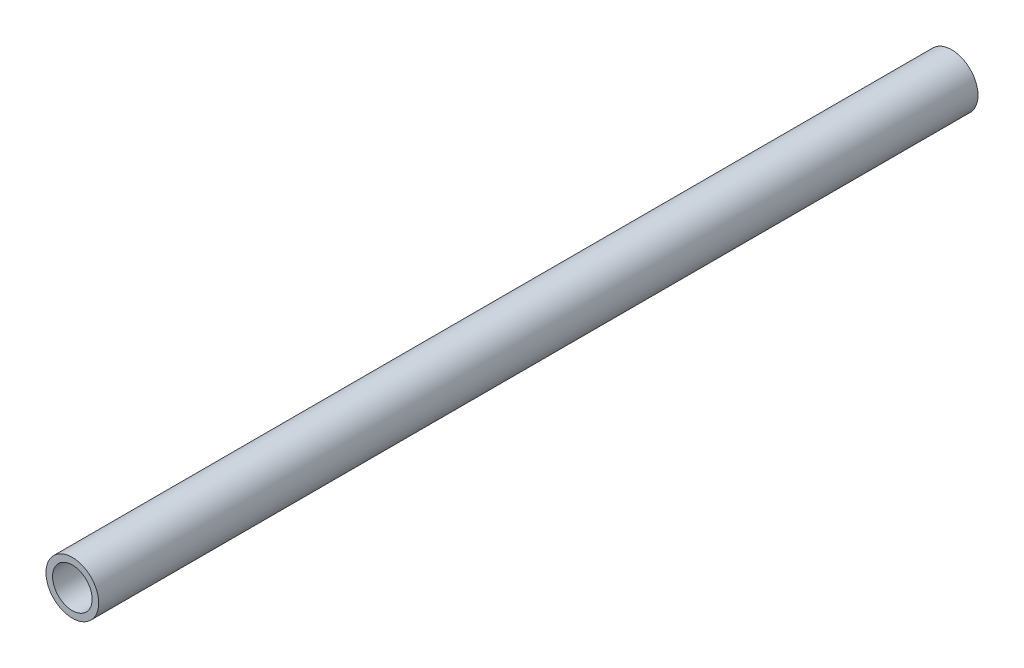
from build123d import *

# Parameters (mm, degrees)
CROQUIS1_R              = 6
SALIENTE_EXTRUIR1_DEPTH = 100
CROQUIS2_R              = 4.5
CORTAR_EXTRUIR1_DEPTH   = 201


with BuildPart() as part:
    # Croquis1 → Saliente-Extruir1 (new body, symmetric)
    with BuildSketch(Plane.XY):
        Circle(CROQUIS1_R)
    extrude(amount=SALIENTE_EXTRUIR1_DEPTH, both=True)

    # Croquis2 → Cortar-Extruir1 (cut, through all)
    with BuildSketch(Plane.XY.offset(100)):
        Circle(CROQUIS2_R)
    extrude(amount=-CORTAR_EXTRUIR1_DEPTH, mode=Mode.SUBTRACT)


solid = part.part
